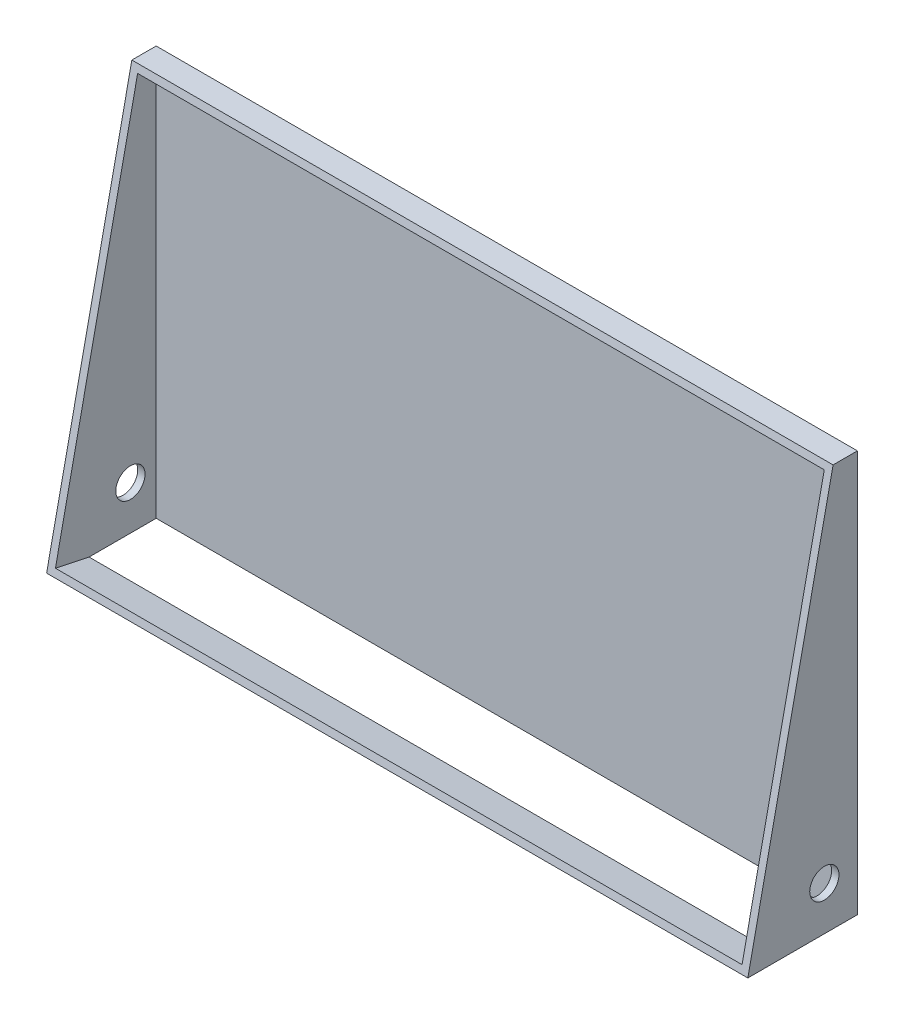
from build123d import *

# Parameters (mm, degrees)
CROQUIS1_W                          = 96
CROQUIS1_H                          = 55
SALIENTE_EXTRUIR2_DEPTH             = 15
CORTAR_EXTRUIR1_DEPTH               = 96
CORTAR_EXTRUIR6_REACH               = 17.673
CORTAR_EXTRUIR6_OFFSET_FROM_SURFACE = 1
CROQUIS4_W                          = 94
CROQUIS4_H                          = 54.224485051
CROQUIS5_R                          = 2
CORTAR_EXTRUIR7_DEPTH               = 97


with BuildPart() as part:
    # Croquis1 → Saliente-Extruir2 (new body)
    with BuildSketch(Plane.XY):
        Rectangle(CROQUIS1_W, CROQUIS1_H)
    extrude(amount=SALIENTE_EXTRUIR2_DEPTH)

    # Croquis2 → Cortar-Extruir1 (cut)
    with BuildSketch(Plane.ZY.offset(48)):
        Polygon((3.329836367, 27.5), (15, 27.5), (15, -27.5), align=None)
    extrude(amount=-CORTAR_EXTRUIR1_DEPTH, mode=Mode.SUBTRACT)

    # Cortar-Extruir6: up to this face of the body (flat: up to its plane, moved by the offset)
    cortar_extruir6_end = Plane(part.part.faces().sort_by_distance((0, 0, 0))[0]).offset(-CORTAR_EXTRUIR6_OFFSET_FROM_SURFACE)
    # Croquis4 → Cortar-Extruir6 (cut, up to the picked face)
    with BuildSketch(Plane(origin=(0, 1.860875227, 8.770068758), x_dir=(1, 0, 0), z_dir=(0, 0.207563726, 0.978221498)), mode=Mode.PRIVATE) as cortar_extruir6_sk1:
        with Locations((0, -1.902304571)):
            Rectangle(CROQUIS4_W, CROQUIS4_H)
    cortar_extruir6_tool1 = split(extrude(cortar_extruir6_sk1.sketch, amount=-CORTAR_EXTRUIR6_REACH, mode=Mode.PRIVATE), bisect_by=cortar_extruir6_end, keep=Keep.BOTH, mode=Mode.PRIVATE)
    add(cortar_extruir6_tool1.solids().sort_by_distance((0, 0, 9.164918))[0], mode=Mode.SUBTRACT)

    # Croquis5 → Cortar-Extruir7 (cut, through all)
    with BuildSketch(Plane.ZY.offset(48)):
        with Locations((4.526520959, -21.5)):
            Circle(CROQUIS5_R)
    extrude(amount=-CORTAR_EXTRUIR7_DEPTH, mode=Mode.SUBTRACT)


solid = part.part
